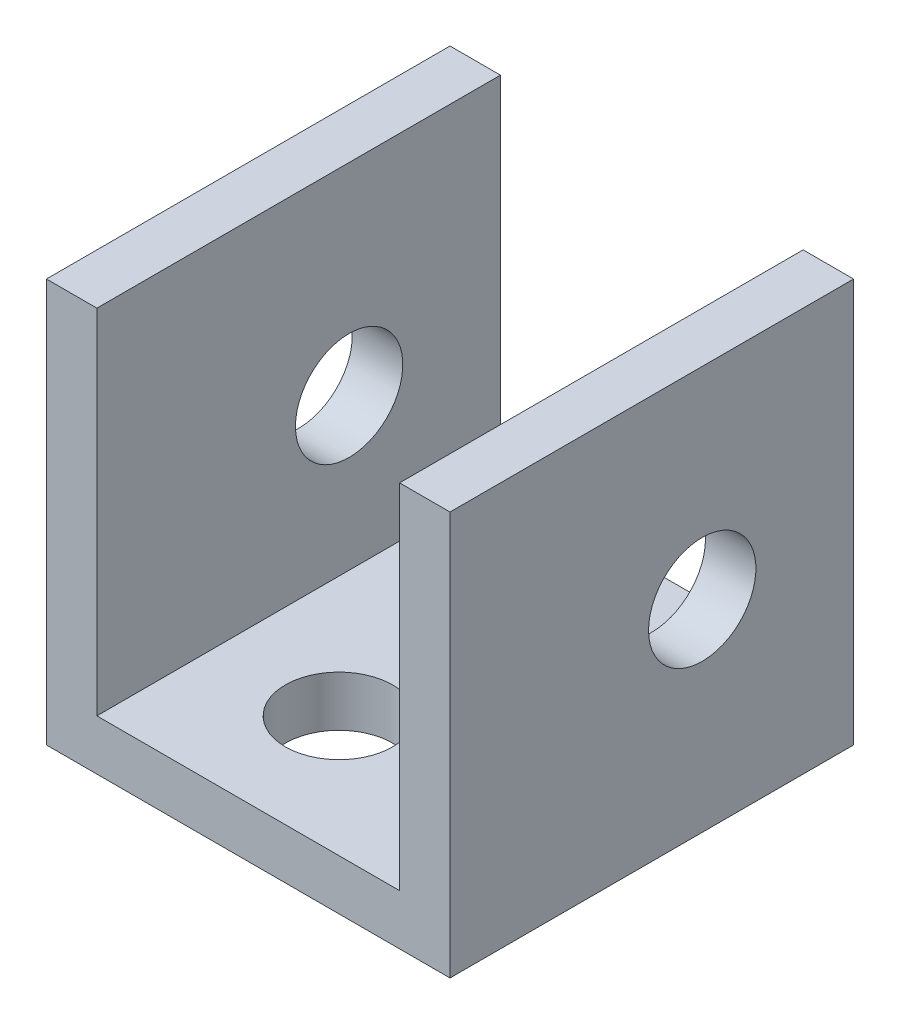
from build123d import *

# Parameters (mm, degrees)
SKETCH1_W               = 25.4
SKETCH1_H               = 25.4
BOSS_EXTRUDE1_DEPTH     = 3.175
SKETCH2_W               = 3.175
SKETCH2_H               = 25.4
BOSS_EXTRUDE2_DEPTH     = 22.225
F_1_4_CLEARANCE_HOLE2_D = 6.7564
F_1_4_CLEARANCE_HOLE1_D = 6.7564


with BuildPart() as part:
    # Sketch1 → Boss-Extrude1 (new body)
    with BuildSketch(Plane(origin=(0, 0, 0), x_dir=(1, 0, 0), z_dir=(0, 1, 0))):
        Rectangle(SKETCH1_W, SKETCH1_H)
    extrude(amount=BOSS_EXTRUDE1_DEPTH)

    # Sketch2 → Boss-Extrude2 (add)
    with BuildSketch(Plane(origin=(0, 3.175, 0), x_dir=(1, 0, 0), z_dir=(0, 1, 0))):
        with Locations((-11.1125, 0)):
            Rectangle(SKETCH2_W, SKETCH2_H)
        with Locations((11.1125, 0)):
            Rectangle(SKETCH2_W, SKETCH2_H)
    extrude(amount=BOSS_EXTRUDE2_DEPTH)

    # 1/4 Clearance Hole2 (through all)
    with Locations(Plane(origin=(0, 3.175, 0), x_dir=(1, 0, 0), z_dir=(0, 1, 0))):
        with Locations((1.905, 5.08), (-1.905, -5.08)):
            Hole(F_1_4_CLEARANCE_HOLE2_D / 2)

    # 1/4 Clearance Hole1 (through all)
    with Locations(Plane.ZY.offset(12.7)):
        with Locations((-3.175, 12.7)):
            Hole(F_1_4_CLEARANCE_HOLE1_D / 2)


solid = part.part
